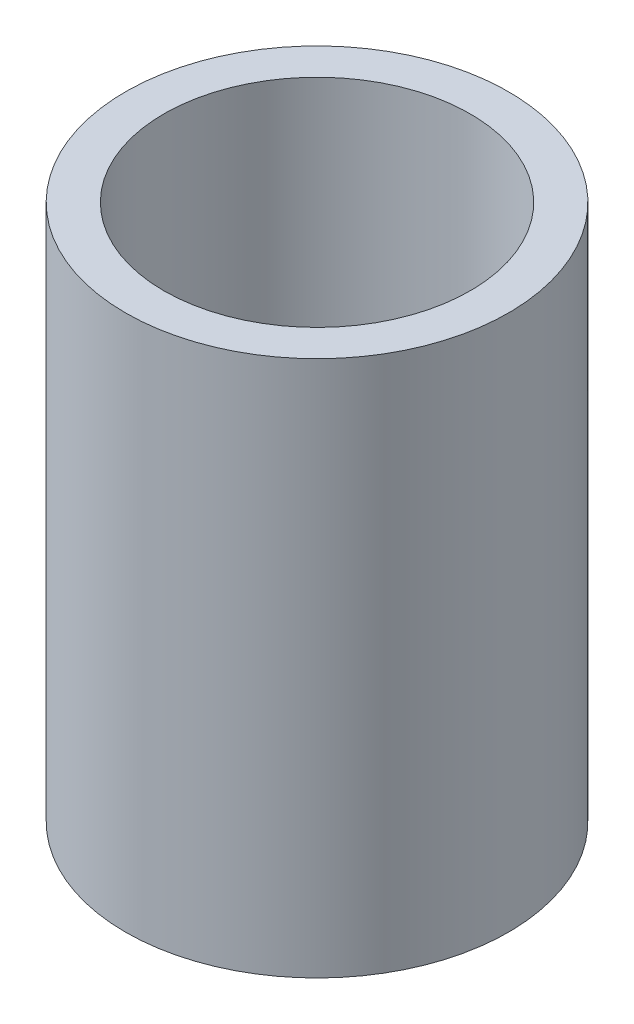
from build123d import *

# Parameters (mm, degrees)
SKETCH1_R           = 5
SKETCH1_R_2         = 4
BOSS_EXTRUDE1_DEPTH = 14


with BuildPart() as part:
    # Sketch1 → Boss-Extrude1 (new body)
    with BuildSketch(Plane(origin=(0, 0, 0), x_dir=(1, 0, 0), z_dir=(0, 1, 0))):
        Circle(SKETCH1_R)
        Circle(SKETCH1_R_2, mode=Mode.SUBTRACT)
    extrude(amount=BOSS_EXTRUDE1_DEPTH)


solid = part.part
